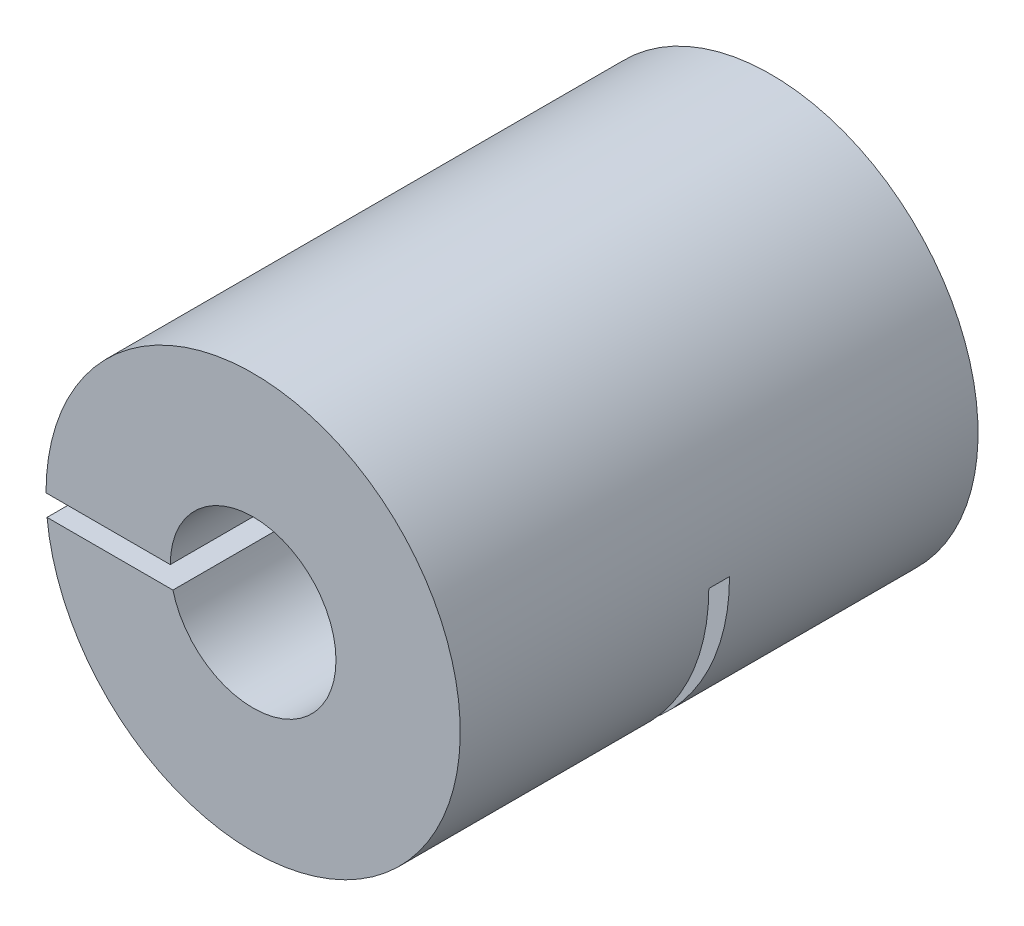
from build123d import *

# Parameters (mm, degrees)
SKETCH_1_R          = 10
EXTRUDE_1_DEPTH     = 12.5
SKETCH_2_R          = 4
CUT_EXTRUDE_1_DEPTH = 12.5
SKETCH_4_W          = 53.049184892
SKETCH_4_H          = 1
CUT_EXTRUDE_2_DEPTH = 25
SKETCH_5_W          = 15.903552991
SKETCH_5_H          = 1
CUT_EXTRUDE_3_DEPTH = 25
SKETCH_6_R          = 2.5
CUT_EXTRUDE_4_DEPTH = 25


with BuildPart() as part:
    # 草图1 → 凸台-拉伸1 (new body, symmetric)
    with BuildSketch(Plane.XY):
        Circle(SKETCH_1_R)
    extrude(amount=EXTRUDE_1_DEPTH, both=True)

    # 草图2 → 切除-拉伸1 (cut)
    with BuildSketch(Plane.XY.offset(12.5)):
        Circle(SKETCH_2_R)
    extrude(amount=-CUT_EXTRUDE_1_DEPTH, mode=Mode.SUBTRACT)

    # 草图4 → 切除-拉伸2 (cut)
    with BuildSketch(Plane(origin=(0, 0, 0), x_dir=(1, 0, 0), z_dir=(0, 1, 0))):
        Rectangle(SKETCH_4_W, SKETCH_4_H)
    extrude(amount=-CUT_EXTRUDE_2_DEPTH, mode=Mode.SUBTRACT)

    # 草图5 → 切除-拉伸3 (cut)
    with BuildSketch(Plane.XY.offset(12.5)):
        with Locations((-7.951776496, -0.5)):
            Rectangle(SKETCH_5_W, SKETCH_5_H)
    extrude(amount=-CUT_EXTRUDE_3_DEPTH, mode=Mode.SUBTRACT)

    # 草图6 → 切除-拉伸4 (cut)
    with BuildSketch(Plane(origin=(0, 0, -12.5), x_dir=(-1, 0, 0), z_dir=(0, 0, -1))):
        Circle(SKETCH_6_R)
    extrude(amount=-CUT_EXTRUDE_4_DEPTH, mode=Mode.SUBTRACT)


solid = part.part
